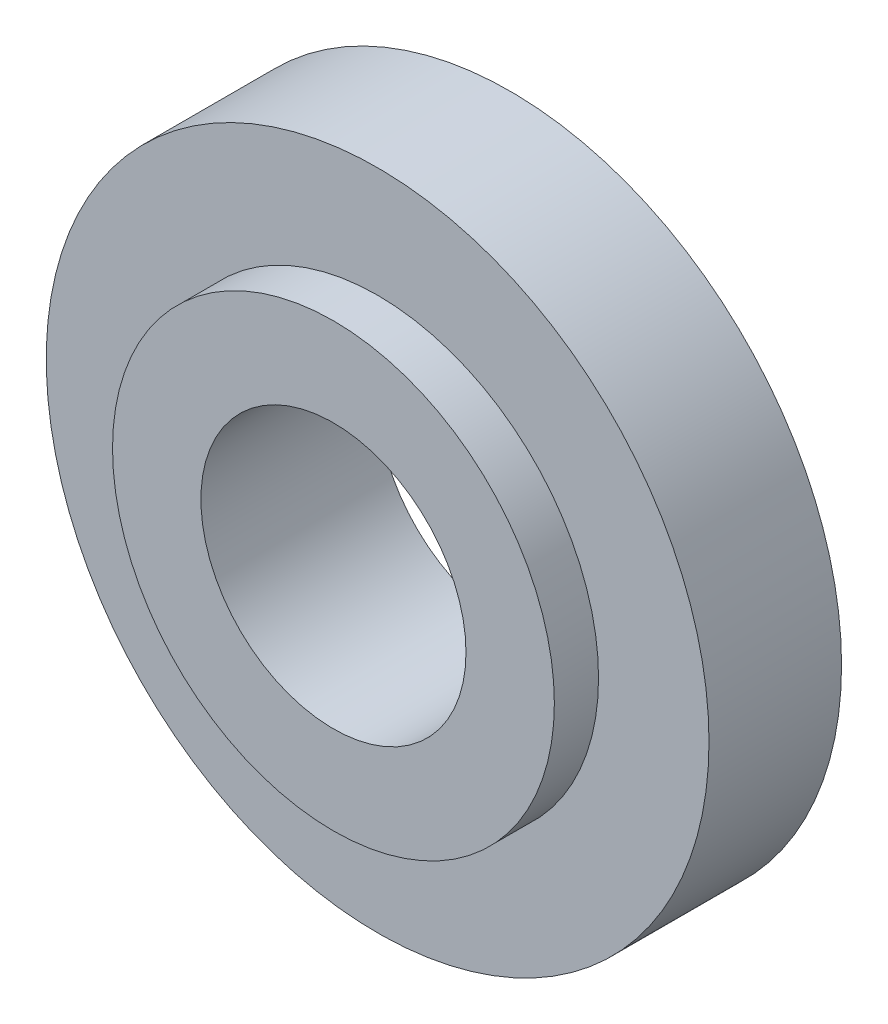
from build123d import *

# Parameters (mm, degrees)
SKETCH1_R           = 3.75
SKETCH1_R_2         = 1.5
BOSS_EXTRUDE1_DEPTH = 1.5
SKETCH2_R           = 2.5
SKETCH2_R_2         = 1.5
BOSS_EXTRUDE2_DEPTH = 0.5
SCALE1_SCALE        = 2


with BuildPart() as part:
    # Sketch1 → Boss-Extrude1 (new body)
    with BuildSketch(Plane.XY):
        Circle(SKETCH1_R)
        Circle(SKETCH1_R_2, mode=Mode.SUBTRACT)
    extrude(amount=BOSS_EXTRUDE1_DEPTH)

    # Sketch2 → Boss-Extrude2 (add)
    with BuildSketch(Plane.XY.offset(1.5)):
        Circle(SKETCH2_R)
        Circle(SKETCH2_R_2, mode=Mode.SUBTRACT)
    extrude(amount=BOSS_EXTRUDE2_DEPTH)


with BuildPart() as part_1:
    # Scale1: scaled about (0, 0, 0.851426307)
    add(part.part.scale(SCALE1_SCALE).moved(Location((0, 0, -0.851426307))))


solid = part_1.part
